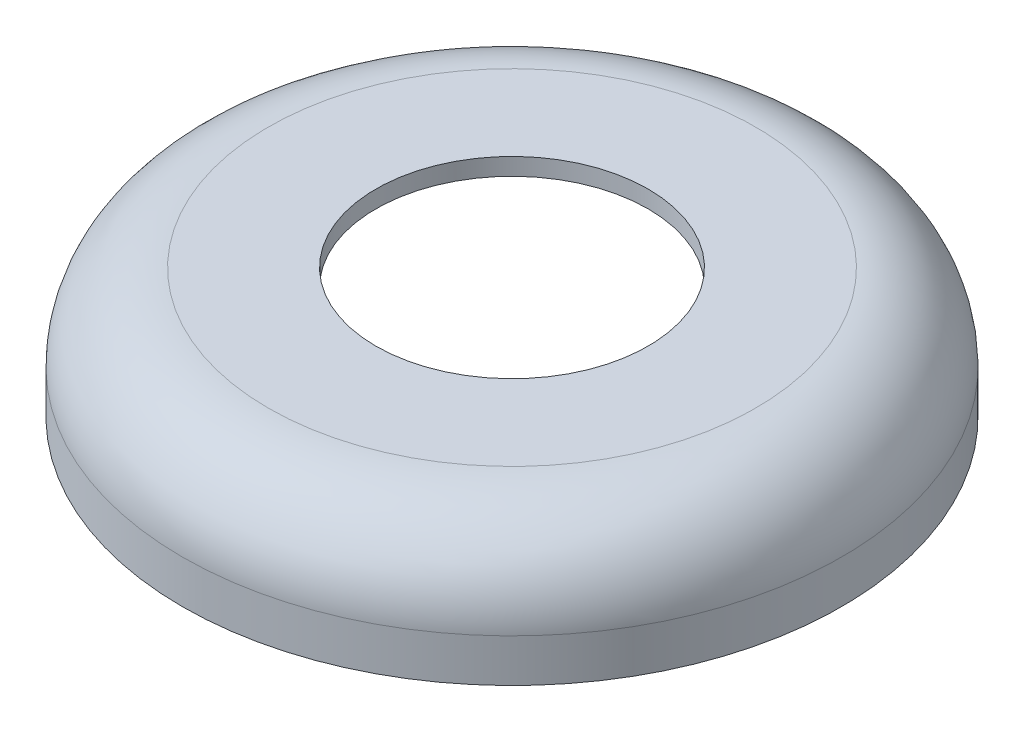
from build123d import *

# Parameters (mm, degrees)
SKETCH2_R           = 11.5
BOSS_EXTRUDE1_DEPTH = 4.5
FILLET1_R           = 3
SHELL1_T            = -0.6
SKETCH3_R           = 4.75
CUT_EXTRUDE1_DEPTH  = 17.874537031


with BuildPart() as part:
    # Sketch2 → Boss-Extrude1 (new body)
    with BuildSketch(Plane(origin=(0, 0, 0), x_dir=(1, 0, 0), z_dir=(0, 1, 0))):
        with Locations(Location((0, 0, 0), (0, 0, 270))):
            Circle(SKETCH2_R)
    extrude(amount=BOSS_EXTRUDE1_DEPTH)

    # Fillet1
    fillet1_edges = [part.edges().sort_by_distance(p)[0] for p in [
        (0, 4.5, -11.5),
    ]]
    fillet(fillet1_edges, radius=FILLET1_R)

    # Shell1
    shell1_openings = [part.faces().sort_by_distance(p)[0] for p in [
        (0, 0, 0),
    ]]
    offset(amount=SHELL1_T, openings=shell1_openings, kind=Kind.INTERSECTION)

    # Sketch3 → Cut-Extrude1 (cut, through all)
    with BuildSketch(Plane(origin=(0, 4.5, 0), x_dir=(1, 0, 0), z_dir=(0, 1, 0))):
        with Locations(Location((0, 0, 0), (0, 0, 270))):
            Circle(SKETCH3_R)
    extrude(amount=-CUT_EXTRUDE1_DEPTH, mode=Mode.SUBTRACT)


solid = part.part
